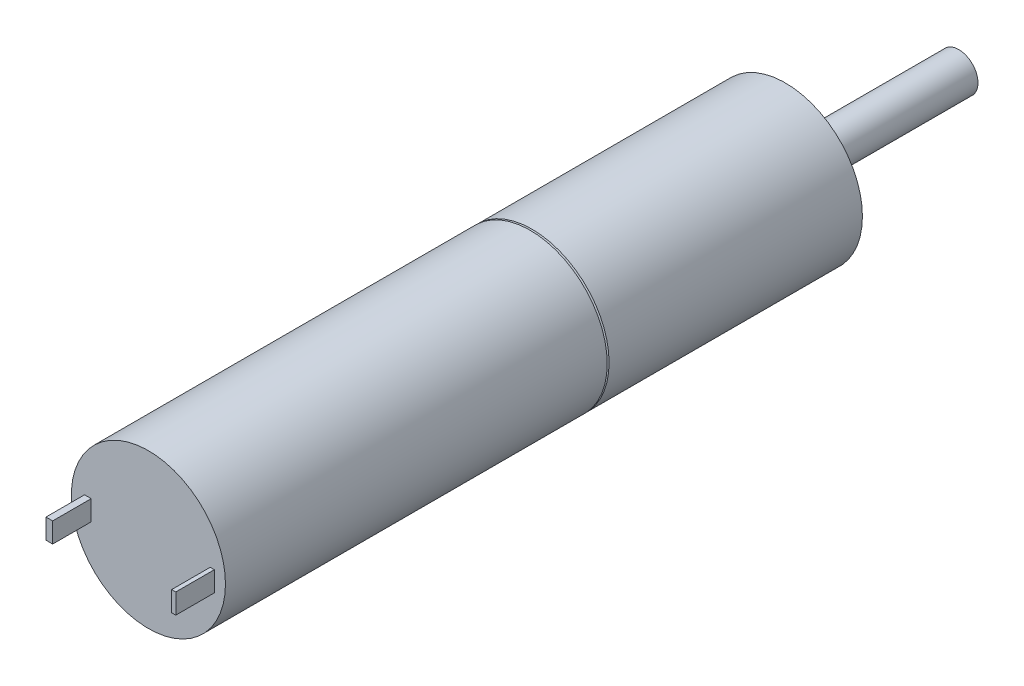
from build123d import *

# Parameters (mm, degrees)
SKETCH1_R           = 6
EXTRUDE1_DEPTH      = 29.8
EXTRUDE1_DEPTH_BACK = 19.8
SKETCH2_W           = 0.322076385
SKETCH2_H           = 1.5639159
SKETCH2_W_2         = 0.519715481
EXTRUDE2_DEPTH      = 3
SKETCH3_R           = 1.5
EXTRUDE3_DEPTH      = 13.5
SKETCH4_R           = 1
CUT_EXTRUDE1_DEPTH  = 13.5


with BuildPart() as part:
    # Sketch1 → Extrude1 (new body, two sides)
    with BuildSketch(Plane.XY) as extrude1_sk:
        Circle(SKETCH1_R)
    extrude(amount=EXTRUDE1_DEPTH)
    extrude(extrude1_sk.sketch, amount=-EXTRUDE1_DEPTH_BACK)

    # Sketch2 → Extrude2 (add)
    with BuildSketch(Plane.XY.offset(29.8)):
        with Locations((4.969715102, -0.2464174)):
            Rectangle(SKETCH2_W, SKETCH2_H)
        with Locations((-4.714918845, -0.2464174)):
            Rectangle(SKETCH2_W_2, SKETCH2_H)
    extrude(amount=EXTRUDE2_DEPTH)

    # Sketch3 → Extrude3 (add)
    with BuildSketch(Plane(origin=(0, 0, -19.8), x_dir=(-1, 0, 0), z_dir=(0, 0, -1))):
        with Locations(Location((0, 0, 0), (0, 0, 180))):  # turned: the seam where the file's is
            Circle(SKETCH3_R)
    extrude(amount=EXTRUDE3_DEPTH)

    # Sketch4 → Cut-Extrude1 (cut)
    with BuildSketch(Plane(origin=(0, 0, -19.8), x_dir=(-1, 0, 0), z_dir=(0, 0, -1))):
        with Locations((4.75, 0)):
            Circle(SKETCH4_R)
        with Locations((-4.75, 0)):
            Circle(SKETCH4_R)
    extrude(amount=-CUT_EXTRUDE1_DEPTH, mode=Mode.SUBTRACT)

    # Sketch6 → Cut-Revolve1 (revolve, cut)
    with BuildSketch(Plane(origin=(0, 0, 0), x_dir=(0, 0, -1), z_dir=(1, 0, 0)), mode=Mode.PRIVATE) as cut_revolve1_sk:
        Polygon((0, 5.8), (0.714830228, 7.76397991), (-0.714830228, 7.76397991), align=None)
    revolve(cut_revolve1_sk.sketch.rotate(Axis((0, 0, 0), (0, 0, 1)), 270), axis=Axis((0, 0, 0), (0, 0, 1)), mode=Mode.SUBTRACT)  # turned: the seam where the file's is


solid = part.part
